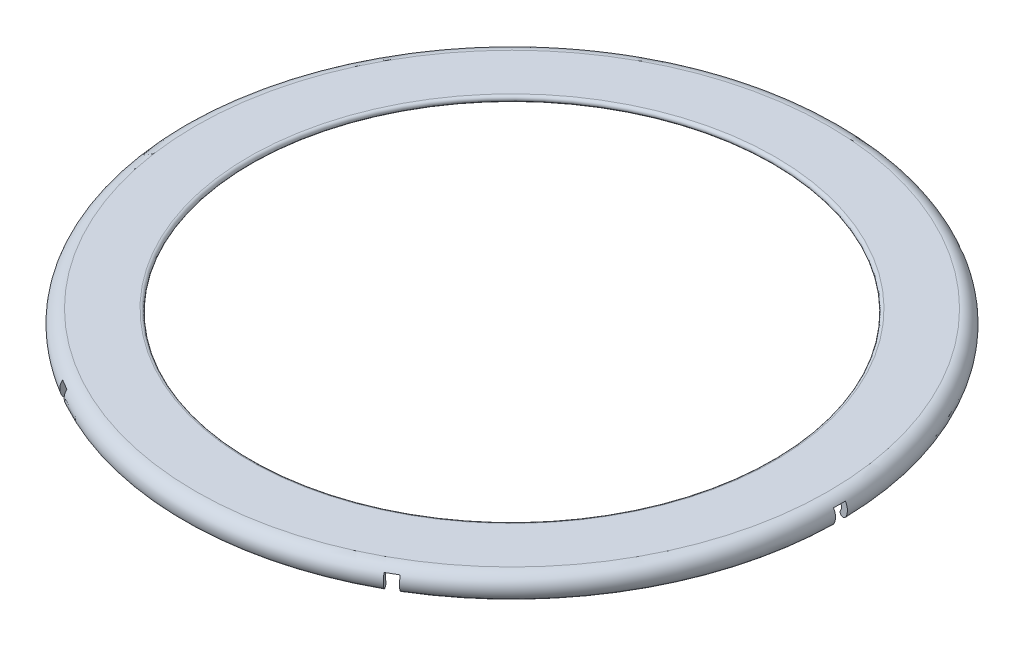
from build123d import *

# Parameters (mm, degrees)
SKETCH2_W          = 76.762463064
SKETCH2_H          = 1
CUT_EXTRUDE1_DEPTH = 11.684
CIRPATTERN1_COUNT  = 3


with BuildPart() as part:
    # Sketch1 → Revolve1 (revolve)
    with BuildSketch(Plane.XY, mode=Mode.PRIVATE) as revolve1_sk:
        with BuildLine():
            Line((-22.164658343, 4.6), (-26.664658343, 4.6))
            ThreePointArc((-26.664658343, 4.6), (-27.617286287, 4.05), (-27.617286287, 2.95))
            ThreePointArc((-27.617286287, 2.95), (-27.275779936, 2.858493649), (-27.184273585, 3.2))
            ThreePointArc((-27.184273585, 3.2), (-27.184273585, 3.8), (-26.664658343, 4.1))
            Line((-26.664658343, 4.1), (-22.164658343, 4.1))
            ThreePointArc((-22.164658343, 4.1), (-21.914658343, 4.35), (-22.164658343, 4.6))
        make_face()
    revolve(revolve1_sk.sketch.rotate(Axis((0, 0, 0), (0, 1, 0)), 270), axis=Axis((0, 0, 0), (0, 1, 0)))

    # Sketch2 → Cut-Extrude1 (cut)
    with BuildSketch(Plane.XZ.offset(-4.1)):
        Rectangle(SKETCH2_W, SKETCH2_H)
    cut_extrude1 = extrude(amount=CUT_EXTRUDE1_DEPTH, mode=Mode.SUBTRACT)

    # CirPattern1: Cut-Extrude1 ×3 about axis
    cirpattern1_axis = Axis((0, 0, 0), (0, 1, 0))
    for i in range(1, CIRPATTERN1_COUNT):
        add(cut_extrude1.rotate(cirpattern1_axis, i * 360 / CIRPATTERN1_COUNT), mode=Mode.SUBTRACT)


solid = part.part
